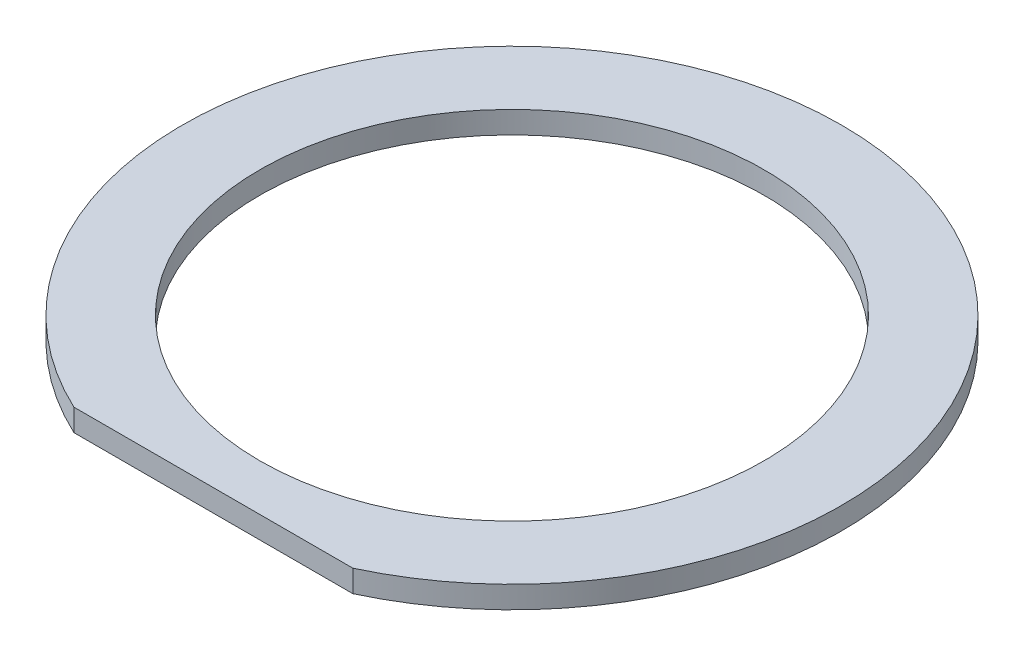
from build123d import *

# Parameters (mm, degrees)
SKETCH1_R          = 14.478
BASE_EXTRUDE_DEPTH = 1.27


with BuildPart() as part:
    # Sketch1 → Base-Extrude (new body)
    with BuildSketch(Plane(origin=(0, 0, 0), x_dir=(1, 0, 0), z_dir=(0, 1, 0))):
        with BuildLine():
            Line((-8.008052447, -17.145), (8.008052447, -17.145))
            ThreePointArc((8.008052447, -17.145), (0, 18.923), (-8.008052447, -17.145))
        make_face()
        Circle(SKETCH1_R, mode=Mode.SUBTRACT)
    extrude(amount=BASE_EXTRUDE_DEPTH)


solid = part.part
